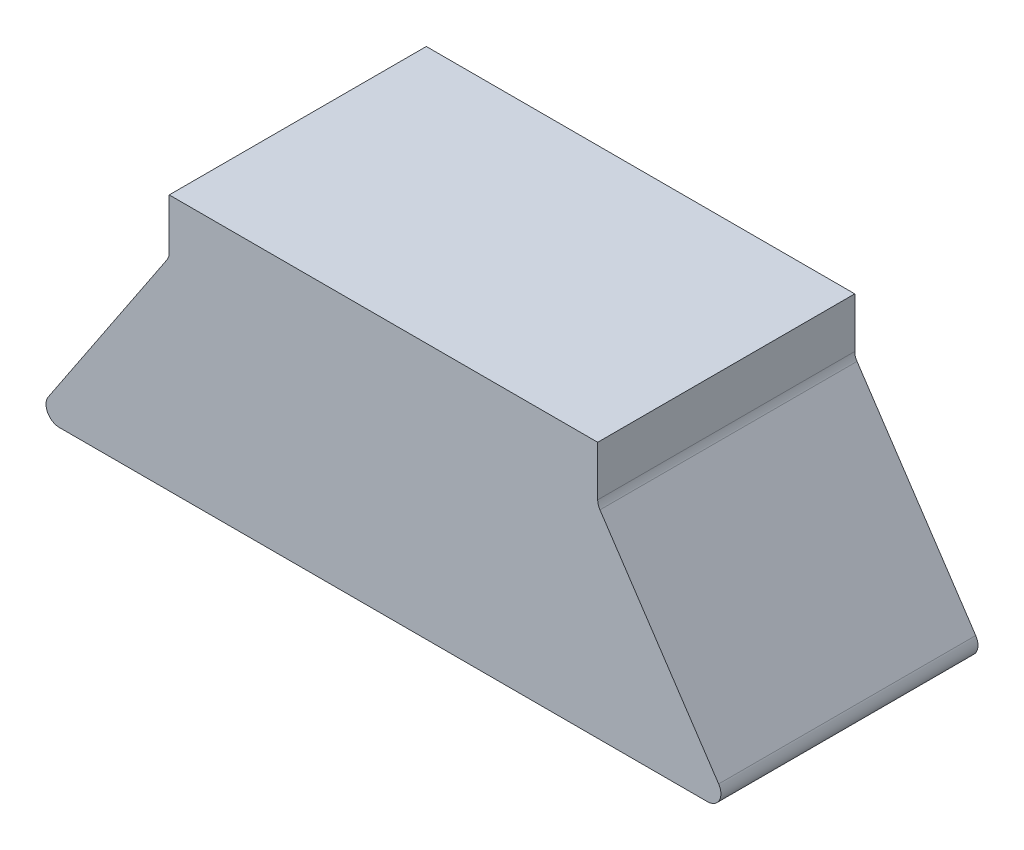
from build123d import *

# Parameters (mm, degrees)
SKETCH1_W           = 31.75
SKETCH1_H           = 19
BOSS_EXTRUDE1_DEPTH = 9.525
BOSS_EXTRUDE2_DEPTH = 19.05
FILLET5_R           = 1


with BuildPart() as part:
    # Sketch1 → Boss-Extrude1 (new body, symmetric)
    with BuildSketch(Plane.XY):
        Rectangle(SKETCH1_W, SKETCH1_H)
    extrude(amount=BOSS_EXTRUDE1_DEPTH, both=True)

    # Sketch3 → Boss-Extrude2 (add)
    with BuildSketch(Plane.XY.offset(9.525)):
        Polygon((-15.875, -9.5), (-25.875, -9.5), (-15.875, 5.5), align=None)
        Polygon((15.875, -9.5), (15.875, 5.5), (25.875, -9.5), align=None)
    extrude(amount=-BOSS_EXTRUDE2_DEPTH)

    # Fillet5
    fillet5_edges = [part.edges().sort_by_distance(p)[0] for p in [
        (-25.875, -9.5, 0),
        (-15.875, 5.5, 0),
        (15.875, 5.5, 0),
        (25.875, -9.5, 0),
    ]]
    fillet(fillet5_edges, radius=FILLET5_R)


solid = part.part
